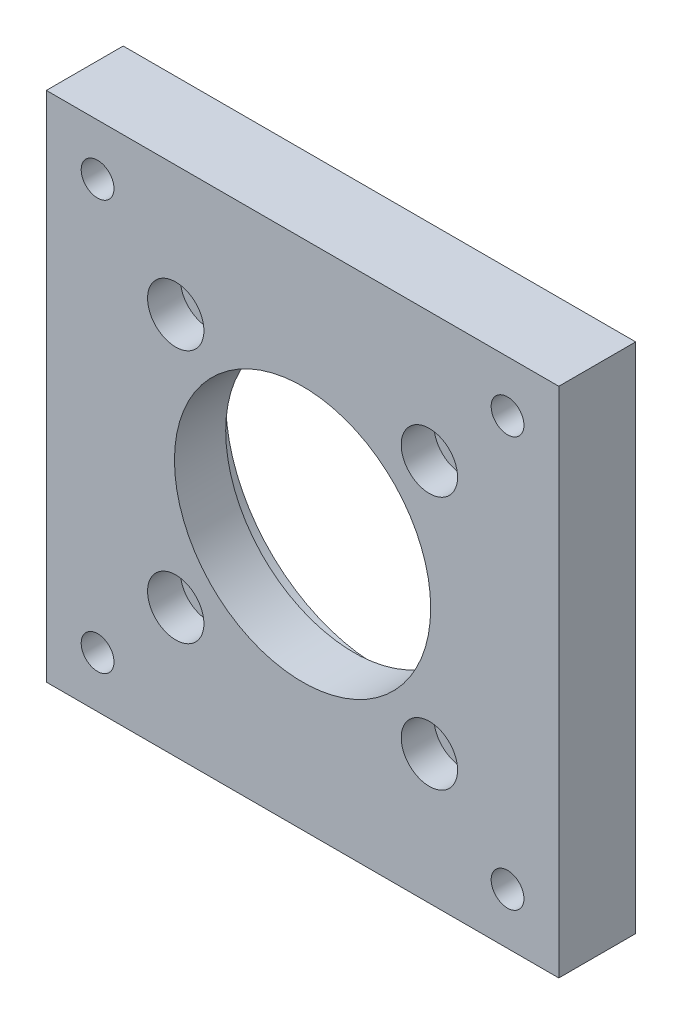
from build123d import *

# Parameters (mm, degrees)
SKETCH_1_W                   = 100
SKETCH_1_H                   = 100
EXTRUDE_1_DEPTH              = 15
HOLE_WIZARD_M6_1_D           = 6.4
HOLE_WIZARD_M6_1_CBORE_D     = 11
HOLE_WIZARD_M6_1_CBORE_DEPTH = 6.4
SKETCH_4_R                   = 30
CUT_EXTRUDE_1_DEPTH          = 5
HOLE_WIZARD_M6_2_D           = 6.4
HOLE_WIZARD_M6_2_CBORE_D     = 11
HOLE_WIZARD_M6_2_CBORE_DEPTH = 6.4
SKETCH_8_R                   = 25
CUT_EXTRUDE_2_DEPTH          = 11


with BuildPart() as part:
    # 草图1 → 凸台-拉伸1 (new body)
    with BuildSketch(Plane.XY):
        Rectangle(SKETCH_1_W, SKETCH_1_H)
    extrude(amount=EXTRUDE_1_DEPTH)

    # M6 六角凹头螺钉的柱形沉头孔1 (through all)
    with Locations(Plane(origin=(-40, 40, 0), x_dir=(-1, 0, 0), z_dir=(0, 0, -1))):
        with Locations((0, 0), (-80, 0), (-80, -80), (0, -80)):
            CounterBoreHole(HOLE_WIZARD_M6_1_D / 2, HOLE_WIZARD_M6_1_CBORE_D / 2, HOLE_WIZARD_M6_1_CBORE_DEPTH)

    # 草图4 → 切除-拉伸1 (cut)
    with BuildSketch(Plane.XY):
        Circle(SKETCH_4_R)
    extrude(amount=CUT_EXTRUDE_1_DEPTH, mode=Mode.SUBTRACT)

    # M6 六角凹头螺钉的柱形沉头孔2 (through all)
    with Locations(Plane(origin=(-24.748737342, 24.748737342, 15), x_dir=(1, 0, 0), z_dir=(0, 0, 1))):
        with Locations((0, 0), (0, -49.497474684), (49.497474684, -49.497474684), (49.497474684, 0)):
            CounterBoreHole(HOLE_WIZARD_M6_2_D / 2, HOLE_WIZARD_M6_2_CBORE_D / 2, HOLE_WIZARD_M6_2_CBORE_DEPTH)

    # 草图8 → 切除-拉伸2 (cut, through all)
    with BuildSketch(Plane(origin=(0, 0, 5), x_dir=(-1, 0, 0), z_dir=(0, 0, -1))):
        Circle(SKETCH_8_R)
    extrude(amount=-CUT_EXTRUDE_2_DEPTH, mode=Mode.SUBTRACT)


solid = part.part
